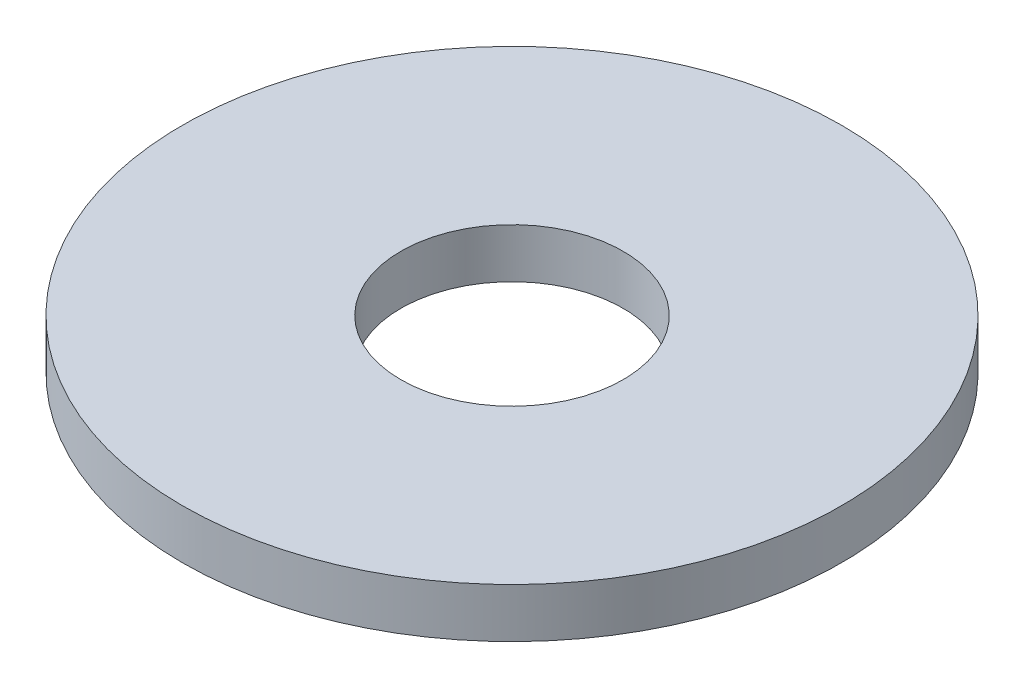
from build123d import *

# Parameters (mm, degrees)
SKETCH1_R           = 40
SKETCH1_R_2         = 13.5
BOSS_EXTRUDE1_DEPTH = 6


with BuildPart() as part:
    # Sketch1 → Boss-Extrude1 (new body)
    with BuildSketch(Plane(origin=(0, 0, 0), x_dir=(1, 0, 0), z_dir=(0, 1, 0))):
        Circle(SKETCH1_R)
        Circle(SKETCH1_R_2, mode=Mode.SUBTRACT)
    extrude(amount=BOSS_EXTRUDE1_DEPTH)


solid = part.part
